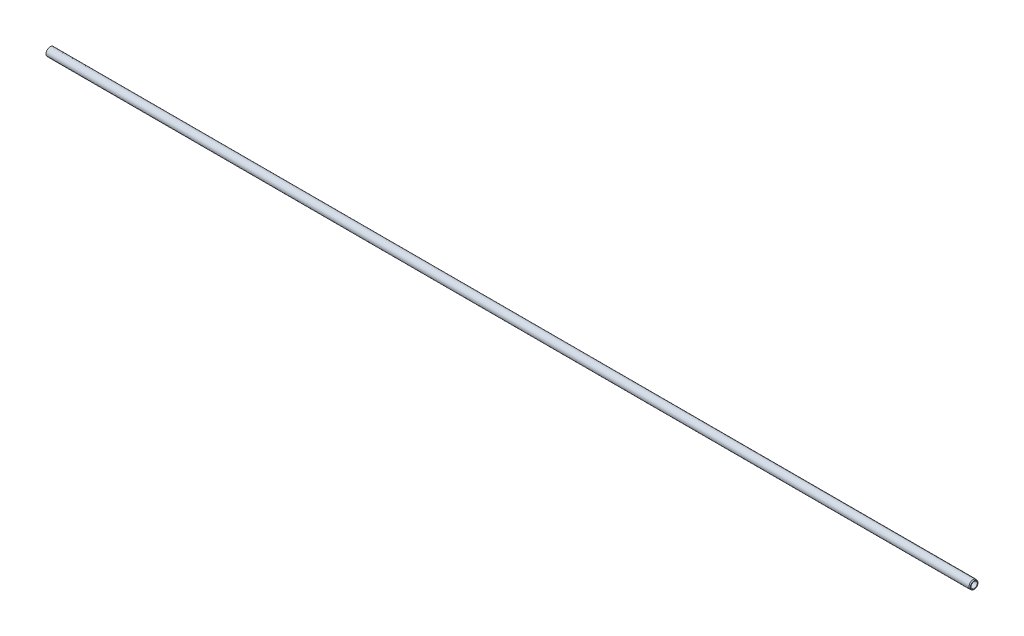
from build123d import *


with BuildPart() as part:
    # Sketch1 → Base-Revolve (revolve)
    with BuildSketch(Plane.XY):
        Polygon((0, 10), (0, 7.5), (2208, 7.5), (2208, 9.090074414), (2205.5, 10), align=None)
    revolve(axis=Axis((0, 0, 0), (1, 0, 0)))


solid = part.part
